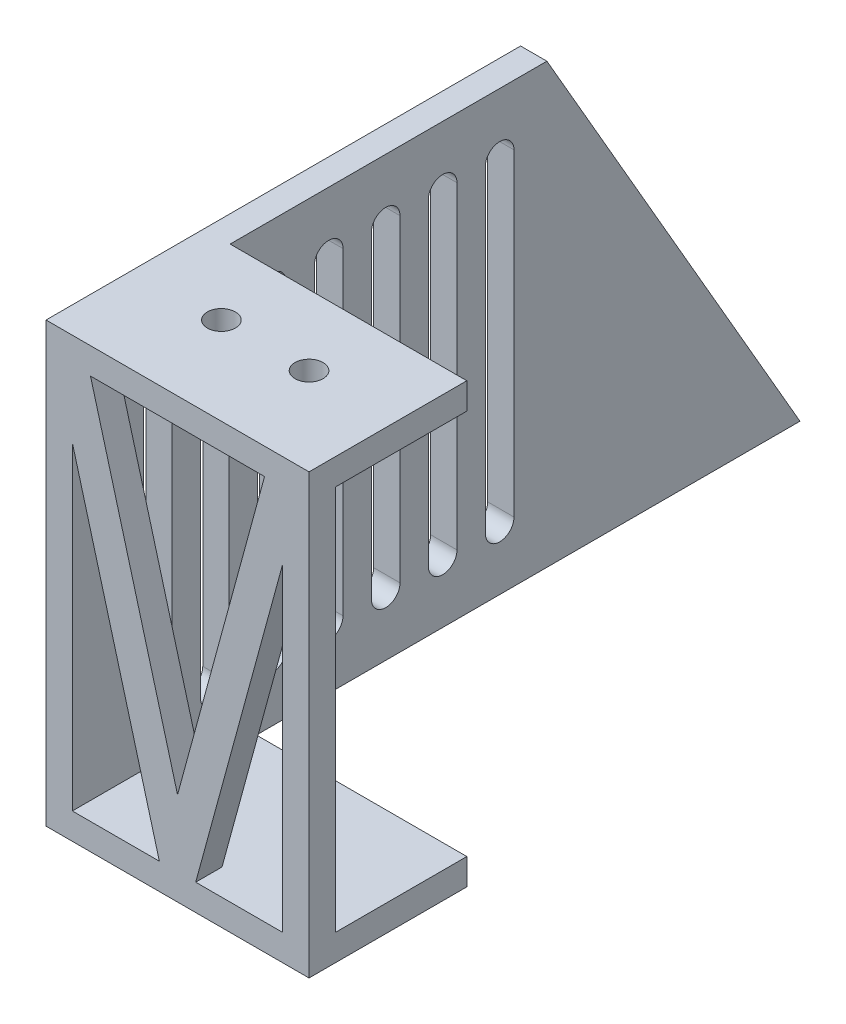
from build123d import *

# Parameters (mm, degrees)
SKETCH_1_W      = 30
SKETCH_1_H      = 50
EXTRUDE_1_DEPTH = 3
EXTRUDE_3_DEPTH = 3
EXTRUDE_START   = -50
SKETCH_3_W      = 27
SKETCH_3_H      = 15
SKETCH_3_R      = 1.6
EXTRUDE_4_DEPTH = 3
SKETCH_5_W      = 27
SKETCH_5_H      = 15
SKETCH_5_R      = 1.6
EXTRUDE_5_DEPTH = 3


with BuildPart() as part:
    # 草图1 → 凸台-拉伸1 (new body)
    with BuildSketch(Plane.XY):
        with Locations((-1.547723223, -1.182673383)):
            Rectangle(SKETCH_1_W, SKETCH_1_H)
        Polygon((-13.547723223, 13.216157116), (-13.547723223, -23.182673383), (-3.620769451, -23.182673383), align=None, mode=Mode.SUBTRACT)
        Polygon((10.452276777, 13.216157116), (10.452276777, -23.182673383), (0.525323004, -23.182673383), align=None, mode=Mode.SUBTRACT)
        Polygon((-11.474676996, 20.817326617), (8.379230549, 20.817326617), (-1.547723223, -15.581503883), align=None, mode=Mode.SUBTRACT)
    extrude(amount=EXTRUDE_1_DEPTH)

    # 草图2 → 凸台-拉伸3 (add)
    with BuildSketch(Plane.ZY.offset(16.547723223)):
        Polygon((-80, -26.182673383), (-51.132486541, 23.817326617), (0, 23.817326617), (0, -26.182673383), align=None)
        Polygon((-3, -23.182673383), (-3, 20.817326617), (-49.400435733, 20.817326617), (-74.803847577, -23.182673383), align=None, mode=Mode.SUBTRACT)
        Polygon((-3, -23.182673383), (-74.803847577, -23.182673383), (-49.400435733, 20.817326617), (-3, 20.817326617), align=None)
        with BuildLine():
            ThreePointArc((-8.378224309, -19.337056165), (-6.74645341, -20.968827063), (-5.114682512, -19.337056165))
            Line((-5.114682512, -19.337056165), (-5.114682512, 16.93515829))
            ThreePointArc((-5.114682512, 16.93515829), (-6.74645341, 18.566929189), (-8.378224309, 16.93515829))
            Line((-8.378224309, 16.93515829), (-8.378224309, -19.337056165))
        make_face(mode=Mode.SUBTRACT)
        with BuildLine():
            ThreePointArc((-14.878224309, -19.337056165), (-13.24645341, -20.968827063), (-11.614682512, -19.337056165))
            Line((-11.614682512, -19.337056165), (-11.614682512, 16.93515829))
            ThreePointArc((-11.614682512, 16.93515829), (-13.24645341, 18.566929189), (-14.878224309, 16.93515829))
            Line((-14.878224309, 16.93515829), (-14.878224309, -19.337056165))
        make_face(mode=Mode.SUBTRACT)
        with BuildLine():
            ThreePointArc((-21.378224309, -19.337056165), (-19.74645341, -20.968827063), (-18.114682512, -19.337056165))
            Line((-18.114682512, -19.337056165), (-18.114682512, 16.93515829))
            ThreePointArc((-18.114682512, 16.93515829), (-19.74645341, 18.566929189), (-21.378224309, 16.93515829))
            Line((-21.378224309, 16.93515829), (-21.378224309, -19.337056165))
        make_face(mode=Mode.SUBTRACT)
        with BuildLine():
            ThreePointArc((-27.878224309, -19.337056165), (-26.24645341, -20.968827063), (-24.614682512, -19.337056165))
            Line((-24.614682512, -19.337056165), (-24.614682512, 16.93515829))
            ThreePointArc((-24.614682512, 16.93515829), (-26.24645341, 18.566929189), (-27.878224309, 16.93515829))
            Line((-27.878224309, 16.93515829), (-27.878224309, -19.337056165))
        make_face(mode=Mode.SUBTRACT)
        with BuildLine():
            ThreePointArc((-34.378224309, -19.337056165), (-32.74645341, -20.968827063), (-31.114682512, -19.337056165))
            Line((-31.114682512, -19.337056165), (-31.114682512, 16.93515829))
            ThreePointArc((-31.114682512, 16.93515829), (-32.74645341, 18.566929189), (-34.378224309, 16.93515829))
            Line((-34.378224309, 16.93515829), (-34.378224309, -19.337056165))
        make_face(mode=Mode.SUBTRACT)
        with BuildLine():
            ThreePointArc((-40.878224309, -19.337056165), (-39.24645341, -20.968827063), (-37.614682512, -19.337056165))
            Line((-37.614682512, -19.337056165), (-37.614682512, 16.93515829))
            ThreePointArc((-37.614682512, 16.93515829), (-39.24645341, 18.566929189), (-40.878224309, 16.93515829))
            Line((-40.878224309, 16.93515829), (-40.878224309, -19.337056165))
        make_face(mode=Mode.SUBTRACT)
        with BuildLine():
            ThreePointArc((-47.378224309, -19.337056165), (-45.74645341, -20.968827063), (-44.114682512, -19.337056165))
            Line((-44.114682512, -19.337056165), (-44.114682512, 16.93515829))
            ThreePointArc((-44.114682512, 16.93515829), (-45.74645341, 18.566929189), (-47.378224309, 16.93515829))
            Line((-47.378224309, 16.93515829), (-47.378224309, -19.337056165))
        make_face(mode=Mode.SUBTRACT)
    extrude(amount=-EXTRUDE_3_DEPTH)

    # 草图3 → 凸台-拉伸4 (add)
    with BuildSketch(Plane(origin=(0, 23.817326617, 0), x_dir=(1, 0, 0), z_dir=(0, 1, 0)).offset(EXTRUDE_START)):
        with Locations((-0.047723223, 7.5)):
            Rectangle(SKETCH_3_W, SKETCH_3_H)
        with Locations((-6.547723223, 7)):
            Circle(SKETCH_3_R, mode=Mode.SUBTRACT)
        with Locations((3.452276777, 7)):
            Circle(SKETCH_3_R, mode=Mode.SUBTRACT)
    extrude(amount=EXTRUDE_4_DEPTH)

    # 草图5 → 凸台-拉伸5 (add)
    with BuildSketch(Plane(origin=(0, 23.817326617, 0), x_dir=(1, 0, 0), z_dir=(0, 1, 0))):
        with Locations((-0.047723223, 7.5)):
            Rectangle(SKETCH_5_W, SKETCH_5_H)
        with Locations((-6.547723223, 7)):
            Circle(SKETCH_5_R, mode=Mode.SUBTRACT)
        with Locations((3.452276777, 7)):
            Circle(SKETCH_5_R, mode=Mode.SUBTRACT)
    extrude(amount=-EXTRUDE_5_DEPTH)


solid = part.part
